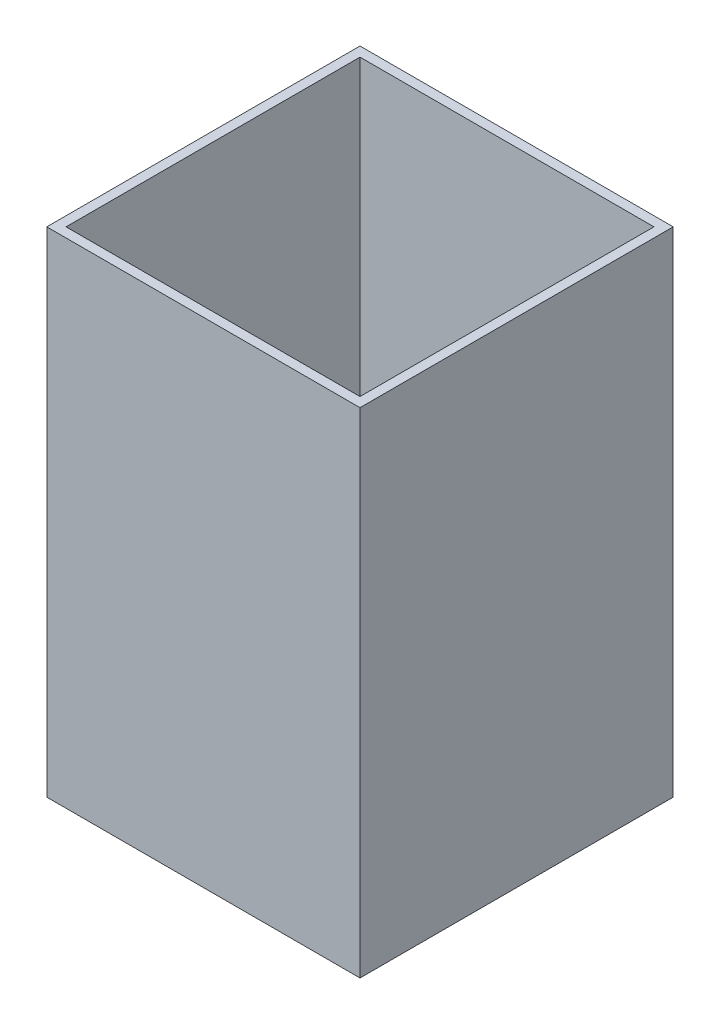
from build123d import *

# Parameters (mm, degrees)
SKETCH1_W           = 82.55
SKETCH1_H           = 82.55
BOSS_EXTRUDE1_DEPTH = 130.175
SHELL1_T            = -2.54


with BuildPart() as part:
    # Sketch1 → Boss-Extrude1 (new body)
    with BuildSketch(Plane(origin=(0, 0, 0), x_dir=(1, 0, 0), z_dir=(0, 1, 0))):
        with Locations((41.275, -41.275)):
            Rectangle(SKETCH1_W, SKETCH1_H)
    extrude(amount=BOSS_EXTRUDE1_DEPTH)

    # Shell1
    shell1_openings = [part.faces().sort_by_distance(p)[0] for p in [
        (41.275, 130.175, 41.275),
    ]]
    offset(amount=SHELL1_T, openings=shell1_openings, kind=Kind.INTERSECTION)


solid = part.part
